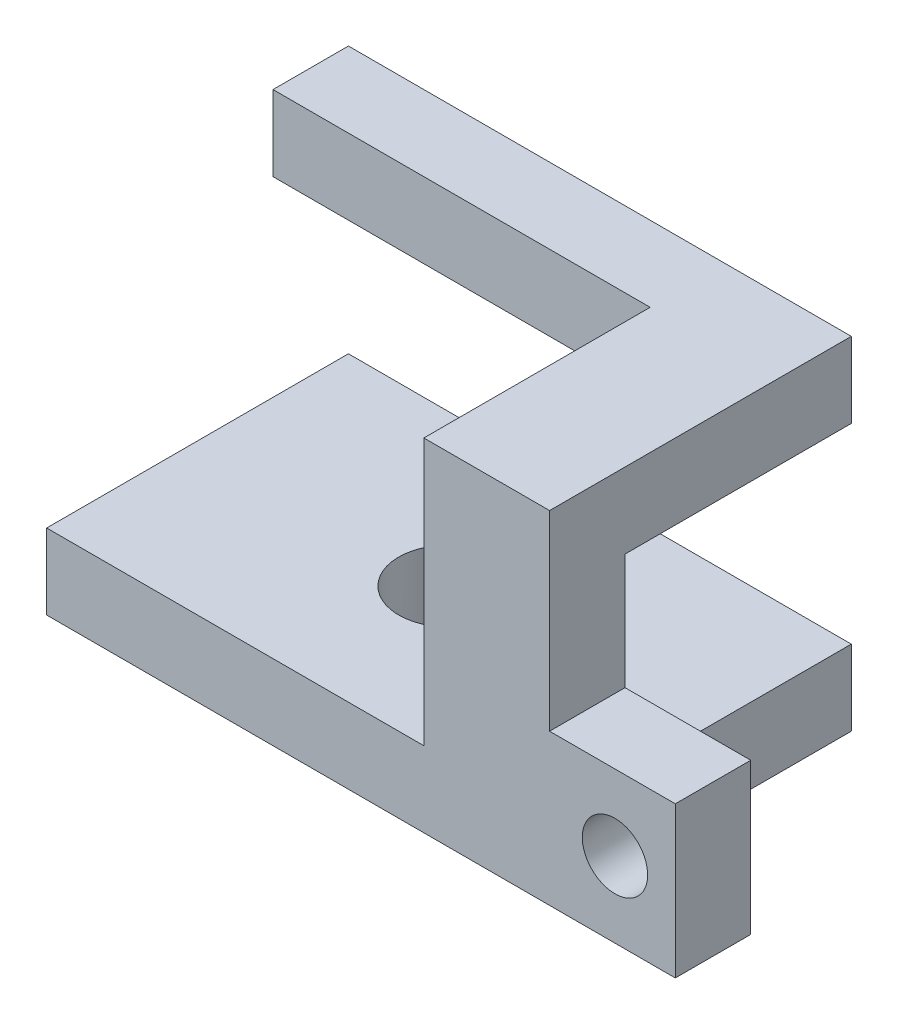
from build123d import *

# Parameters (mm, degrees)
SKETCH1_R           = 10
BOSS_EXTRUDE1_DEPTH = 68
SKETCH3_W           = 45
SKETCH3_H           = 38
CUT_EXTRUDE1_DEPTH  = 126
SKETCH4_W           = 75
SKETCH4_H           = 45
SKETCH4_W_2         = 25
CUT_EXTRUDE2_DEPTH  = 53
SKETCH4_2_W         = 25
SKETCH4_2_H         = 45
CUT_EXTRUDE3_DEPTH  = 69
SKETCH5_R           = 6.5
SKETCH5_W           = 25
SKETCH5_H           = 38
CUT_EXTRUDE4_DEPTH  = 16


with BuildPart() as part:
    # Sketch1 → Boss-Extrude1 (new body)
    with BuildSketch(Plane(origin=(0, 0, 0), x_dir=(1, 0, 0), z_dir=(0, 1, 0))):
        Polygon((-50, -30), (50, -30), (75, -30), (75, 30), (50, 30), (-50, 30), align=None)
        Circle(SKETCH1_R, mode=Mode.SUBTRACT)
    extrude(amount=BOSS_EXTRUDE1_DEPTH)

    # Sketch3 → Cut-Extrude1 (cut, through all)
    with BuildSketch(Plane(origin=(75, 0, 0), x_dir=(0, 0, -1), z_dir=(1, 0, 0))):
        with Locations((7.5, 34)):
            Rectangle(SKETCH3_W, SKETCH3_H)
    extrude(amount=-CUT_EXTRUDE1_DEPTH, mode=Mode.SUBTRACT)

    # Sketch4 → Cut-Extrude2 (cut)
    with BuildSketch(Plane(origin=(0, 68, 0), x_dir=(1, 0, 0), z_dir=(0, 1, 0))):
        with Locations((-12.5, -7.5)):
            Rectangle(SKETCH4_W, SKETCH4_H)
        with Locations((62.5, 7.5)):
            Rectangle(SKETCH4_W_2, SKETCH4_H)
    extrude(amount=-CUT_EXTRUDE2_DEPTH, mode=Mode.SUBTRACT)

    # Sketch4_2 → Cut-Extrude3 (cut, through all)
    with BuildSketch(Plane(origin=(0, 68, 0), x_dir=(1, 0, 0), z_dir=(0, 1, 0))):
        with Locations((62.5, 7.5)):
            Rectangle(SKETCH4_2_W, SKETCH4_2_H)
    extrude(amount=-CUT_EXTRUDE3_DEPTH, mode=Mode.SUBTRACT)

    # Sketch5 → Cut-Extrude4 (cut, through all)
    with BuildSketch(Plane(origin=(0, 0, 15), x_dir=(-1, 0, 0), z_dir=(0, 0, -1))):
        with Locations((-63, 15)):
            Circle(SKETCH5_R)
        with Locations((-62.5, 49)):
            Rectangle(SKETCH5_W, SKETCH5_H)
    extrude(amount=-CUT_EXTRUDE4_DEPTH, mode=Mode.SUBTRACT)


solid = part.part
